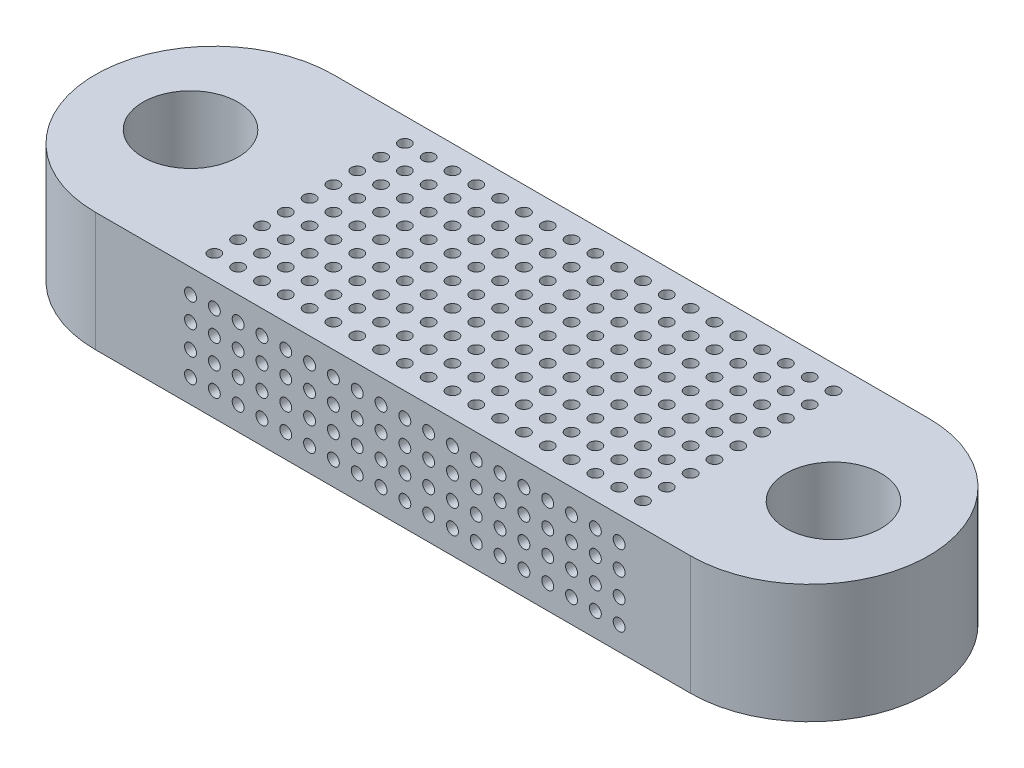
from build123d import *

# Parameters (mm, degrees)
SKETCH1_W             = 50
SKETCH1_H             = 20
BOSS_EXTRUDE1_DEPTH   = 10
SKETCH2_R             = 10
BOSS_EXTRUDE2_DEPTH   = 10
SKETCH3_R             = 10
BOSS_EXTRUDE3_DEPTH   = 10
SKETCH4_R             = 4
CUT_EXTRUDE1_DEPTH    = 11
SKETCH5_R             = 4
CUT_EXTRUDE2_DEPTH    = 11
SKETCH6_R             = 0.5
CUT_EXTRUDE3_DEPTH    = 11
SKETCH7_R             = 0.5
CUT_EXTRUDE4_DEPTH    = 11
SKETCH8_R             = 0.5
CUT_EXTRUDE5_DEPTH    = 11
SKETCH9_R             = 0.5
CUT_EXTRUDE6_DEPTH    = 11
SKETCH10_R            = 0.5
CUT_EXTRUDE7_DEPTH    = 11
SKETCH11_R            = 0.5
CUT_EXTRUDE8_DEPTH    = 10
SKETCH12_R            = 0.5
CUT_EXTRUDE9_DEPTH    = 11
SKETCH13_R            = 0.5
CUT_EXTRUDE10_DEPTH   = 11
SKETCH15_R            = 0.5
CUT_EXTRUDE14_DEPTH   = 11
LPATTERN2_COUNT       = 11
LPATTERN2_PITCH       = 2
SKETCH16_R            = 0.5
CUT_EXTRUDE15_DEPTH   = 11
LPATTERN3_COUNT       = 19
LPATTERN3_PITCH       = 2
SKETCH17_R            = 0.5
CUT_EXTRUDE16_DEPTH   = 11
LPATTERN4_COUNT       = 19
LPATTERN4_PITCH       = 2
SKETCH18_R            = 0.5
CUT_EXTRUDE17_DEPTH   = 11
SKETCH19_R            = 0.5
CUT_EXTRUDE18_DEPTH   = 11
SKETCH20_R            = 0.5
CUT_EXTRUDE19_DEPTH   = 11
LPATTERN5_COUNT       = 19
LPATTERN5_PITCH       = 2
LPATTERN6_COUNT       = 19
LPATTERN6_PITCH       = 2
LPATTERN7_COUNT       = 19
LPATTERN7_PITCH       = 2
SKETCH21_R            = 0.5
CUT_EXTRUDE20_DEPTH   = 11
SKETCH22_R            = 0.5
CUT_EXTRUDE21_DEPTH   = 11
SKETCH23_R            = 0.5
CUT_EXTRUDE22_DEPTH   = 11
LPATTERN8_COUNT       = 19
LPATTERN8_PITCH       = 2
LPATTERN9_COUNT       = 19
LPATTERN9_PITCH       = 2
LPATTERN10_COUNT      = 19
LPATTERN10_PITCH      = 2
SKETCH25_R            = 0.5
CUT_EXTRUDE24_DEPTH   = 21
LPATTERN13_COUNT      = 4
LPATTERN13_PITCH      = 2
LPATTERN13_COUNT_DIR2 = 19
LPATTERN13_PITCH_DIR2 = 2


with BuildPart() as part:
    # Sketch1 → Boss-Extrude1 (new body)
    with BuildSketch(Plane(origin=(0, 0, 0), x_dir=(1, 0, 0), z_dir=(0, 1, 0))):
        with Locations((25, 10)):
            Rectangle(SKETCH1_W, SKETCH1_H)
    extrude(amount=BOSS_EXTRUDE1_DEPTH)

    # Sketch2 → Boss-Extrude2 (add)
    with BuildSketch(Plane(origin=(0, 10, 0), x_dir=(1, 0, 0), z_dir=(0, 1, 0))):
        with Locations((0, 10)):
            Circle(SKETCH2_R)
    extrude(amount=-BOSS_EXTRUDE2_DEPTH)

    # Sketch3 → Boss-Extrude3 (add)
    with BuildSketch(Plane(origin=(0, 10, 0), x_dir=(1, 0, 0), z_dir=(0, 1, 0))):
        with Locations((50, 10)):
            Circle(SKETCH3_R)
    extrude(amount=-BOSS_EXTRUDE3_DEPTH)

    # Sketch4 → Cut-Extrude1 (cut, through all)
    with BuildSketch(Plane(origin=(0, 10, 0), x_dir=(1, 0, 0), z_dir=(0, 1, 0))):
        with Locations((52, 10)):
            Circle(SKETCH4_R)
    extrude(amount=-CUT_EXTRUDE1_DEPTH, mode=Mode.SUBTRACT)

    # Sketch5 → Cut-Extrude2 (cut, through all)
    with BuildSketch(Plane(origin=(0, 10, 0), x_dir=(1, 0, 0), z_dir=(0, 1, 0))):
        with Locations((-2, 10)):
            Circle(SKETCH5_R)
    extrude(amount=-CUT_EXTRUDE2_DEPTH, mode=Mode.SUBTRACT)

    # Sketch6 → Cut-Extrude3 (cut, through all)
    with BuildSketch(Plane(origin=(0, 10, 0), x_dir=(1, 0, 0), z_dir=(0, 1, 0))):
        with Locations((8, 2)):
            Circle(SKETCH6_R)
    extrude(amount=-CUT_EXTRUDE3_DEPTH, mode=Mode.SUBTRACT)

    # Sketch7 → Cut-Extrude4 (cut, through all)
    with BuildSketch(Plane(origin=(0, 10, 0), x_dir=(1, 0, 0), z_dir=(0, 1, 0))):
        with Locations((10, 2)):
            Circle(SKETCH7_R)
    extrude(amount=-CUT_EXTRUDE4_DEPTH, mode=Mode.SUBTRACT)

    # Sketch8 → Cut-Extrude5 (cut, through all)
    with BuildSketch(Plane(origin=(0, 10, 0), x_dir=(1, 0, 0), z_dir=(0, 1, 0))):
        with Locations((12, 2)):
            Circle(SKETCH8_R)
    extrude(amount=-CUT_EXTRUDE5_DEPTH, mode=Mode.SUBTRACT)

    # Sketch9 → Cut-Extrude6 (cut, through all)
    with BuildSketch(Plane(origin=(0, 10, 0), x_dir=(1, 0, 0), z_dir=(0, 1, 0))):
        with Locations((14, 2)):
            Circle(SKETCH9_R)
    extrude(amount=-CUT_EXTRUDE6_DEPTH, mode=Mode.SUBTRACT)

    # Sketch10 → Cut-Extrude7 (cut, through all)
    with BuildSketch(Plane(origin=(0, 10, 0), x_dir=(1, 0, 0), z_dir=(0, 1, 0))):
        with Locations((16, 2)):
            Circle(SKETCH10_R)
    extrude(amount=-CUT_EXTRUDE7_DEPTH, mode=Mode.SUBTRACT)

    # Sketch11 → Cut-Extrude8 (cut)
    with BuildSketch(Plane(origin=(0, 10, 0), x_dir=(1, 0, 0), z_dir=(0, 1, 0))):
        with Locations((18, 2)):
            Circle(SKETCH11_R)
    extrude(amount=-CUT_EXTRUDE8_DEPTH, mode=Mode.SUBTRACT)

    # Sketch12 → Cut-Extrude9 (cut, through all)
    with BuildSketch(Plane(origin=(0, 10, 0), x_dir=(1, 0, 0), z_dir=(0, 1, 0))):
        with Locations((20, 2)):
            Circle(SKETCH12_R)
    extrude(amount=-CUT_EXTRUDE9_DEPTH, mode=Mode.SUBTRACT)

    # Sketch13 → Cut-Extrude10 (cut, through all)
    with BuildSketch(Plane(origin=(0, 10, 0), x_dir=(1, 0, 0), z_dir=(0, 1, 0))):
        with Locations((22, 2)):
            Circle(SKETCH13_R)
    extrude(amount=-CUT_EXTRUDE10_DEPTH, mode=Mode.SUBTRACT)

    # Sketch15 → Cut-Extrude14 (cut, through all)
    with BuildSketch(Plane(origin=(0, 10, 0), x_dir=(1, 0, 0), z_dir=(0, 1, 0))):
        with Locations((24, 2)):
            Circle(SKETCH15_R)
    cut_extrude14 = extrude(amount=-CUT_EXTRUDE14_DEPTH, mode=Mode.SUBTRACT)

    # LPattern2: Cut-Extrude14 ×11
    with Locations(*[(i * LPATTERN2_PITCH, 0, 0) for i in range(1, LPATTERN2_COUNT)]):
        add(cut_extrude14, mode=Mode.SUBTRACT)

    # Sketch16 → Cut-Extrude15 (cut, through all)
    with BuildSketch(Plane(origin=(0, 10, 0), x_dir=(1, 0, 0), z_dir=(0, 1, 0))):
        with Locations((8, 4)):
            Circle(SKETCH16_R)
    cut_extrude15 = extrude(amount=-CUT_EXTRUDE15_DEPTH, mode=Mode.SUBTRACT)

    # LPattern3: Cut-Extrude15 ×19
    with Locations(*[(i * LPATTERN3_PITCH, 0, 0) for i in range(1, LPATTERN3_COUNT)]):
        add(cut_extrude15, mode=Mode.SUBTRACT)

    # Sketch17 → Cut-Extrude16 (cut, through all)
    with BuildSketch(Plane(origin=(0, 10, 0), x_dir=(1, 0, 0), z_dir=(0, 1, 0))):
        with Locations((8, 6)):
            Circle(SKETCH17_R)
    cut_extrude16 = extrude(amount=-CUT_EXTRUDE16_DEPTH, mode=Mode.SUBTRACT)

    # LPattern4: Cut-Extrude16 ×19
    with Locations(*[(i * LPATTERN4_PITCH, 0, 0) for i in range(1, LPATTERN4_COUNT)]):
        add(cut_extrude16, mode=Mode.SUBTRACT)

    # Sketch18 → Cut-Extrude17 (cut, through all)
    with BuildSketch(Plane(origin=(0, 10, 0), x_dir=(1, 0, 0), z_dir=(0, 1, 0))):
        with Locations((8, 8)):
            Circle(SKETCH18_R)
    cut_extrude17 = extrude(amount=-CUT_EXTRUDE17_DEPTH, mode=Mode.SUBTRACT)

    # Sketch19 → Cut-Extrude18 (cut, through all)
    with BuildSketch(Plane(origin=(0, 10, 0), x_dir=(1, 0, 0), z_dir=(0, 1, 0))):
        with Locations((8, 10)):
            Circle(SKETCH19_R)
    cut_extrude18 = extrude(amount=-CUT_EXTRUDE18_DEPTH, mode=Mode.SUBTRACT)

    # Sketch20 → Cut-Extrude19 (cut, through all)
    with BuildSketch(Plane(origin=(0, 10, 0), x_dir=(1, 0, 0), z_dir=(0, 1, 0))):
        with Locations((8, 12)):
            Circle(SKETCH20_R)
    cut_extrude19 = extrude(amount=-CUT_EXTRUDE19_DEPTH, mode=Mode.SUBTRACT)

    # LPattern5: Cut-Extrude17 ×19
    with Locations(*[(i * LPATTERN5_PITCH, 0, 0) for i in range(1, LPATTERN5_COUNT)]):
        add(cut_extrude17, mode=Mode.SUBTRACT)

    # LPattern6: Cut-Extrude18 ×19
    with Locations(*[(i * LPATTERN6_PITCH, 0, 0) for i in range(1, LPATTERN6_COUNT)]):
        add(cut_extrude18, mode=Mode.SUBTRACT)

    # LPattern7: Cut-Extrude19 ×19
    with Locations(*[(i * LPATTERN7_PITCH, 0, 0) for i in range(1, LPATTERN7_COUNT)]):
        add(cut_extrude19, mode=Mode.SUBTRACT)

    # Sketch21 → Cut-Extrude20 (cut, through all)
    with BuildSketch(Plane(origin=(0, 10, 0), x_dir=(1, 0, 0), z_dir=(0, 1, 0))):
        with Locations((8, 14)):
            Circle(SKETCH21_R)
    cut_extrude20 = extrude(amount=-CUT_EXTRUDE20_DEPTH, mode=Mode.SUBTRACT)

    # Sketch22 → Cut-Extrude21 (cut, through all)
    with BuildSketch(Plane(origin=(0, 10, 0), x_dir=(1, 0, 0), z_dir=(0, 1, 0))):
        with Locations((8, 16)):
            Circle(SKETCH22_R)
    cut_extrude21 = extrude(amount=-CUT_EXTRUDE21_DEPTH, mode=Mode.SUBTRACT)

    # Sketch23 → Cut-Extrude22 (cut, through all)
    with BuildSketch(Plane(origin=(0, 10, 0), x_dir=(1, 0, 0), z_dir=(0, 1, 0))):
        with Locations((8, 18)):
            Circle(SKETCH23_R)
    cut_extrude22 = extrude(amount=-CUT_EXTRUDE22_DEPTH, mode=Mode.SUBTRACT)

    # LPattern8: Cut-Extrude20 ×19
    with Locations(*[(i * LPATTERN8_PITCH, 0, 0) for i in range(1, LPATTERN8_COUNT)]):
        add(cut_extrude20, mode=Mode.SUBTRACT)

    # LPattern9: Cut-Extrude21 ×19
    with Locations(*[(i * LPATTERN9_PITCH, 0, 0) for i in range(1, LPATTERN9_COUNT)]):
        add(cut_extrude21, mode=Mode.SUBTRACT)

    # LPattern10: Cut-Extrude22 ×19
    with Locations(*[(i * LPATTERN10_PITCH, 0, 0) for i in range(1, LPATTERN10_COUNT)]):
        add(cut_extrude22, mode=Mode.SUBTRACT)

    # Sketch25 → Cut-Extrude24 (cut, through all)
    with BuildSketch(Plane.XY):
        with Locations((8, 8)):
            Circle(SKETCH25_R)
    cut_extrude24 = extrude(amount=-CUT_EXTRUDE24_DEPTH, mode=Mode.SUBTRACT)

    # LPattern13: Cut-Extrude24 4 × 19
    with Locations(*[(j * LPATTERN13_PITCH_DIR2, -i * LPATTERN13_PITCH, 0) for i in range(LPATTERN13_COUNT) for j in range(LPATTERN13_COUNT_DIR2) if (i, j) != (0, 0)]):
        add(cut_extrude24, mode=Mode.SUBTRACT)


solid = part.part
